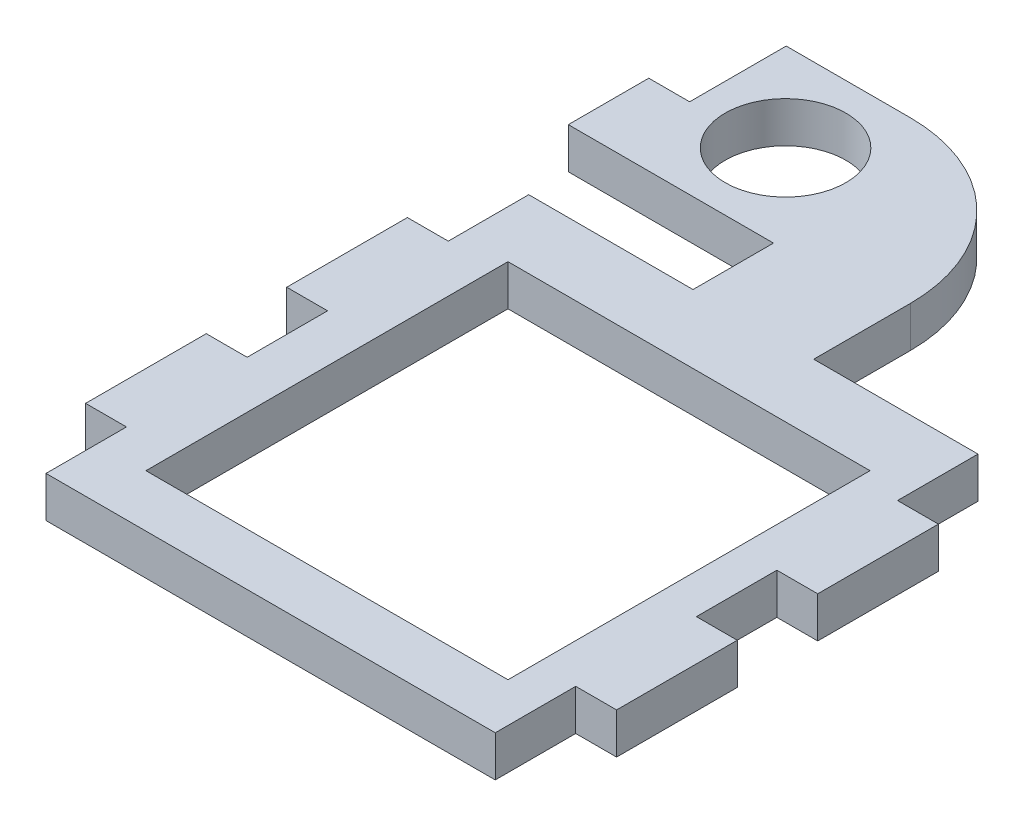
from build123d import *

# Parameters (mm, degrees)
SKETCH1_W           = 55.84
SKETCH1_H           = 60
SKETCH1_W_2         = 45
SKETCH1_H_2         = 45
BOSS_EXTRUDE1_DEPTH = 5.08
SKETCH2_W           = 5.08
SKETCH2_H           = 15
BOSS_EXTRUDE2_DEPTH = 5.08
SKETCH3_R           = 7.5
BOSS_EXTRUDE3_DEPTH = 5.08
FILLET1_R           = 20
SKETCH4_W           = 5.08
SKETCH4_H           = 12
CUT_EXTRUDE1_DEPTH  = 6.08


with BuildPart() as part:
    # Sketch1 → Boss-Extrude1 (new body)
    with BuildSketch(Plane(origin=(0, 0, 0), x_dir=(1, 0, 0), z_dir=(0, 1, 0))):
        Rectangle(SKETCH1_W, SKETCH1_H)
        with Locations((0.5, -1)):
            Rectangle(SKETCH1_W_2, SKETCH1_H_2, mode=Mode.SUBTRACT)
    extrude(amount=BOSS_EXTRUDE1_DEPTH)

    # Sketch2 → Boss-Extrude2 (add)
    with BuildSketch(Plane(origin=(0, 5.08, 0), x_dir=(1, 0, 0), z_dir=(0, 1, 0))):
        with Locations((-30.46, -12.5)):
            Rectangle(SKETCH2_W, SKETCH2_H)
        with Locations((30.46, -12.5)):
            Rectangle(SKETCH2_W, SKETCH2_H)
        with Locations((-30.46, 12.5)):
            Rectangle(SKETCH2_W, SKETCH2_H)
        with Locations((30.46, 12.5)):
            Rectangle(SKETCH2_W, SKETCH2_H)
    extrude(amount=-BOSS_EXTRUDE2_DEPTH)

    # Sketch3 → Boss-Extrude3 (add)
    with BuildSketch(Plane(origin=(0, 5.08, 0), x_dir=(1, 0, 0), z_dir=(0, 1, 0))):
        Polygon((-7.5, 30), (7.5, 30), (7.5, 40), (7.5, 62), (-33, 62), (-33, 40), (-7.5, 40), align=None)
        with Locations((-17, 51)):
            Circle(SKETCH3_R, mode=Mode.SUBTRACT)
    extrude(amount=-BOSS_EXTRUDE3_DEPTH)

    # Fillet1
    fillet1_edges = [part.edges().sort_by_distance(p)[0] for p in [
        (7.5, 2.54, -62),
    ]]
    fillet(fillet1_edges, radius=FILLET1_R)

    # Sketch4 → Cut-Extrude1 (cut, through all)
    with BuildSketch(Plane(origin=(0, 5.08, 0), x_dir=(1, 0, 0), z_dir=(0, 1, 0))):
        with Locations((-30.46, 56)):
            Rectangle(SKETCH4_W, SKETCH4_H)
    extrude(amount=-CUT_EXTRUDE1_DEPTH, mode=Mode.SUBTRACT)


solid = part.part
